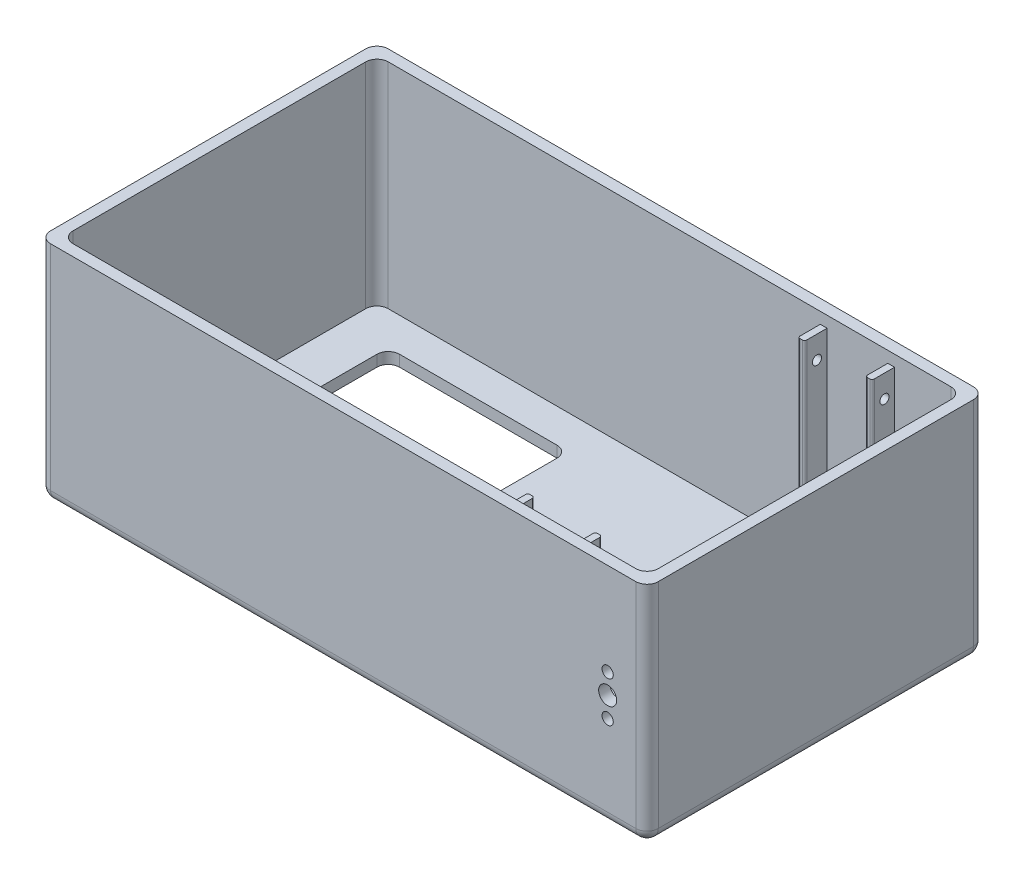
from build123d import *

# Parameters (mm, degrees)
SKETCH1_W               = 270
SKETCH1_H               = 150
OUTER_BOX_DEPTH         = 100
SKETCH2_W               = 260
SKETCH2_H               = 140
INNER_BOX_DEPTH         = 95
FILLET2_R               = 5
SKETCH3_W               = 80
SKETCH3_H               = 110
SCREEN_HOLE_DEPTH       = 77
FILLET3_R               = 5
SKETCH4_R               = 4
SKETCH4_R_2             = 2.5
WHEEL_HOLES_DEPTH       = 151
SKETCH5_R               = 14.5
CUT_EXTRUDE4_DEPTH      = 101
SKETCH9_R               = 1
CUT_EXTRUDE5_DEPTH      = 101
SKETCH10_W              = 3
SKETCH10_H              = 90
BOSS_EXTRUDE2_DEPTH     = 10
SKETCH11_W              = 3
SKETCH11_H              = 90
BOSS_EXTRUDE3_DEPTH     = 10
LPATTERN1_COUNT         = 2
LPATTERN1_PITCH         = 30
FILLET4_R               = 1
SKETCH13_R              = 2.024928201
SKETCH13_R_2            = 2
CUT_EXTRUDE6_DEPTH      = 60
CUT_EXTRUDE6_DEPTH_BACK = 11
SKETCH14_R              = 2
CUT_EXTRUDE7_DEPTH      = 63
CUT_EXTRUDE7_DEPTH_BACK = 16


with BuildPart() as part:
    # Sketch1 → Outer Box (new body)
    with BuildSketch(Plane(origin=(0, 0, 0), x_dir=(1, 0, 0), z_dir=(0, 1, 0))):
        Rectangle(SKETCH1_W, SKETCH1_H)
    extrude(amount=OUTER_BOX_DEPTH)

    # Sketch2 → Inner Box (cut)
    with BuildSketch(Plane(origin=(0, 100, 0), x_dir=(1, 0, 0), z_dir=(0, 1, 0))):
        Rectangle(SKETCH2_W, SKETCH2_H)
    extrude(amount=-INNER_BOX_DEPTH, mode=Mode.SUBTRACT)

    # Fillet2
    fillet2_edges = [part.edges().sort_by_distance(p)[0] for p in [
        (130, 52.5, 70),
        (-130, 52.5, 70),
        (-130, 52.5, -70),
        (130, 52.5, -70),
        (0, 0, 75),
        (-135, 0, 0),
        (0, 0, -75),
        (135, 0, 0),
        (135, 50, 75),
        (-135, 50, 75),
        (-135, 50, -75),
        (135, 50, -75),
    ]]
    fillet(fillet2_edges, radius=FILLET2_R)

    # Sketch3 → Screen Hole (cut)
    with BuildSketch(Plane.XZ):
        with Locations((-70, 0)):
            Rectangle(SKETCH3_W, SKETCH3_H)
    extrude(amount=-SCREEN_HOLE_DEPTH, mode=Mode.SUBTRACT)

    # Fillet3
    fillet3_edges = [part.edges().sort_by_distance(p)[0] for p in [
        (-110, 2.5, -55),
        (-110, 2.5, 55),
        (-30, 2.5, 55),
        (-30, 2.5, -55),
    ]]
    fillet(fillet3_edges, radius=FILLET3_R)

    # Sketch4 → Wheel Holes (cut, through all)
    with BuildSketch(Plane.XY.offset(75)):
        with Locations((117.5, 50)):
            Circle(SKETCH4_R)
        with Locations((117.5, 41)):
            Circle(SKETCH4_R_2)
        with Locations((117.5, 59)):
            Circle(SKETCH4_R_2)
    extrude(amount=-WHEEL_HOLES_DEPTH, mode=Mode.SUBTRACT)

    # Sketch5 → Cut-Extrude4 (cut, through all)
    with BuildSketch(Plane.XZ):
        Circle(SKETCH5_R)
    extrude(amount=-CUT_EXTRUDE4_DEPTH, mode=Mode.SUBTRACT)

    # Sketch9 → Cut-Extrude5 (cut, through all)
    with BuildSketch(Plane.XZ):
        with Locations((22.718468805, 62.780351251)):
            Circle(SKETCH9_R)
        with Locations((26.718468805, 62.780351251)):
            Circle(SKETCH9_R)
        with Locations((30.718468805, 62.780351251)):
            Circle(SKETCH9_R)
        with Locations((34.718468805, 62.780351251)):
            Circle(SKETCH9_R)
        with Locations((38.718468805, 62.780351251)):
            Circle(SKETCH9_R)
        with Locations((42.718468805, 62.780351251)):
            Circle(SKETCH9_R)
        with Locations((46.718468805, 62.780351251)):
            Circle(SKETCH9_R)
        with Locations((50.718468805, 62.780351251)):
            Circle(SKETCH9_R)
        with Locations((54.718468805, 62.780351251)):
            Circle(SKETCH9_R)
        with Locations((58.718468805, 62.780351251)):
            Circle(SKETCH9_R)
        with Locations((26.718468805, 57.780351251)):
            Circle(SKETCH9_R)
        with Locations((30.718468805, 57.780351251)):
            Circle(SKETCH9_R)
        with Locations((34.718468805, 57.780351251)):
            Circle(SKETCH9_R)
        with Locations((38.718468805, 57.780351251)):
            Circle(SKETCH9_R)
        with Locations((42.718468805, 57.780351251)):
            Circle(SKETCH9_R)
        with Locations((46.718468805, 57.780351251)):
            Circle(SKETCH9_R)
        with Locations((50.718468805, 57.780351251)):
            Circle(SKETCH9_R)
        with Locations((54.718468805, 57.780351251)):
            Circle(SKETCH9_R)
        with Locations((58.718468805, 57.780351251)):
            Circle(SKETCH9_R)
        with Locations((26.718468805, 52.780351251)):
            Circle(SKETCH9_R)
        with Locations((30.718468805, 52.780351251)):
            Circle(SKETCH9_R)
        with Locations((34.718468805, 52.780351251)):
            Circle(SKETCH9_R)
        with Locations((38.718468805, 52.780351251)):
            Circle(SKETCH9_R)
        with Locations((42.718468805, 52.780351251)):
            Circle(SKETCH9_R)
        with Locations((46.718468805, 52.780351251)):
            Circle(SKETCH9_R)
        with Locations((50.718468805, 52.780351251)):
            Circle(SKETCH9_R)
        with Locations((54.718468805, 52.780351251)):
            Circle(SKETCH9_R)
        with Locations((58.718468805, 52.780351251)):
            Circle(SKETCH9_R)
        with Locations((26.718468805, 47.780351251)):
            Circle(SKETCH9_R)
        with Locations((30.718468805, 47.780351251)):
            Circle(SKETCH9_R)
        with Locations((34.718468805, 47.780351251)):
            Circle(SKETCH9_R)
        with Locations((38.718468805, 47.780351251)):
            Circle(SKETCH9_R)
        with Locations((42.718468805, 47.780351251)):
            Circle(SKETCH9_R)
        with Locations((46.718468805, 47.780351251)):
            Circle(SKETCH9_R)
        with Locations((50.718468805, 47.780351251)):
            Circle(SKETCH9_R)
        with Locations((54.718468805, 47.780351251)):
            Circle(SKETCH9_R)
        with Locations((58.718468805, 47.780351251)):
            Circle(SKETCH9_R)
        with Locations((26.718468805, 42.780351251)):
            Circle(SKETCH9_R)
        with Locations((30.718468805, 42.780351251)):
            Circle(SKETCH9_R)
        with Locations((34.718468805, 42.780351251)):
            Circle(SKETCH9_R)
        with Locations((38.718468805, 42.780351251)):
            Circle(SKETCH9_R)
        with Locations((42.718468805, 42.780351251)):
            Circle(SKETCH9_R)
        with Locations((46.718468805, 42.780351251)):
            Circle(SKETCH9_R)
        with Locations((50.718468805, 42.780351251)):
            Circle(SKETCH9_R)
        with Locations((54.718468805, 42.780351251)):
            Circle(SKETCH9_R)
        with Locations((58.718468805, 42.780351251)):
            Circle(SKETCH9_R)
        with Locations((26.718468805, 37.780351251)):
            Circle(SKETCH9_R)
        with Locations((30.718468805, 37.780351251)):
            Circle(SKETCH9_R)
        with Locations((34.718468805, 37.780351251)):
            Circle(SKETCH9_R)
        with Locations((38.718468805, 37.780351251)):
            Circle(SKETCH9_R)
        with Locations((42.718468805, 37.780351251)):
            Circle(SKETCH9_R)
        with Locations((46.718468805, 37.780351251)):
            Circle(SKETCH9_R)
        with Locations((50.718468805, 37.780351251)):
            Circle(SKETCH9_R)
        with Locations((54.718468805, 37.780351251)):
            Circle(SKETCH9_R)
        with Locations((58.718468805, 37.780351251)):
            Circle(SKETCH9_R)
        with Locations((26.718468805, 32.780351251)):
            Circle(SKETCH9_R)
        with Locations((30.718468805, 32.780351251)):
            Circle(SKETCH9_R)
        with Locations((34.718468805, 32.780351251)):
            Circle(SKETCH9_R)
        with Locations((38.718468805, 32.780351251)):
            Circle(SKETCH9_R)
        with Locations((42.718468805, 32.780351251)):
            Circle(SKETCH9_R)
        with Locations((46.718468805, 32.780351251)):
            Circle(SKETCH9_R)
        with Locations((50.718468805, 32.780351251)):
            Circle(SKETCH9_R)
        with Locations((54.718468805, 32.780351251)):
            Circle(SKETCH9_R)
        with Locations((58.718468805, 32.780351251)):
            Circle(SKETCH9_R)
        with Locations((26.718468805, 27.780351251)):
            Circle(SKETCH9_R)
        with Locations((30.718468805, 27.780351251)):
            Circle(SKETCH9_R)
        with Locations((34.718468805, 27.780351251)):
            Circle(SKETCH9_R)
        with Locations((38.718468805, 27.780351251)):
            Circle(SKETCH9_R)
        with Locations((42.718468805, 27.780351251)):
            Circle(SKETCH9_R)
        with Locations((46.718468805, 27.780351251)):
            Circle(SKETCH9_R)
        with Locations((50.718468805, 27.780351251)):
            Circle(SKETCH9_R)
        with Locations((54.718468805, 27.780351251)):
            Circle(SKETCH9_R)
        with Locations((58.718468805, 27.780351251)):
            Circle(SKETCH9_R)
        with Locations((26.718468805, 22.780351251)):
            Circle(SKETCH9_R)
        with Locations((30.718468805, 22.780351251)):
            Circle(SKETCH9_R)
        with Locations((34.718468805, 22.780351251)):
            Circle(SKETCH9_R)
        with Locations((38.718468805, 22.780351251)):
            Circle(SKETCH9_R)
        with Locations((42.718468805, 22.780351251)):
            Circle(SKETCH9_R)
        with Locations((46.718468805, 22.780351251)):
            Circle(SKETCH9_R)
        with Locations((50.718468805, 22.780351251)):
            Circle(SKETCH9_R)
        with Locations((54.718468805, 22.780351251)):
            Circle(SKETCH9_R)
        with Locations((58.718468805, 22.780351251)):
            Circle(SKETCH9_R)
        with Locations((26.718468805, 17.780351251)):
            Circle(SKETCH9_R)
        with Locations((30.718468805, 17.780351251)):
            Circle(SKETCH9_R)
        with Locations((34.718468805, 17.780351251)):
            Circle(SKETCH9_R)
        with Locations((38.718468805, 17.780351251)):
            Circle(SKETCH9_R)
        with Locations((42.718468805, 17.780351251)):
            Circle(SKETCH9_R)
        with Locations((46.718468805, 17.780351251)):
            Circle(SKETCH9_R)
        with Locations((50.718468805, 17.780351251)):
            Circle(SKETCH9_R)
        with Locations((54.718468805, 17.780351251)):
            Circle(SKETCH9_R)
        with Locations((58.718468805, 17.780351251)):
            Circle(SKETCH9_R)
        with Locations((26.718468805, 12.780351251)):
            Circle(SKETCH9_R)
        with Locations((30.718468805, 12.780351251)):
            Circle(SKETCH9_R)
        with Locations((34.718468805, 12.780351251)):
            Circle(SKETCH9_R)
        with Locations((38.718468805, 12.780351251)):
            Circle(SKETCH9_R)
        with Locations((42.718468805, 12.780351251)):
            Circle(SKETCH9_R)
        with Locations((46.718468805, 12.780351251)):
            Circle(SKETCH9_R)
        with Locations((50.718468805, 12.780351251)):
            Circle(SKETCH9_R)
        with Locations((54.718468805, 12.780351251)):
            Circle(SKETCH9_R)
        with Locations((58.718468805, 12.780351251)):
            Circle(SKETCH9_R)
        with Locations((22.718468805, 57.780351251)):
            Circle(SKETCH9_R)
        with Locations((22.718468805, 52.780351251)):
            Circle(SKETCH9_R)
        with Locations((22.718468805, 47.780351251)):
            Circle(SKETCH9_R)
        with Locations((22.718468805, 42.780351251)):
            Circle(SKETCH9_R)
        with Locations((22.718468805, 37.780351251)):
            Circle(SKETCH9_R)
        with Locations((22.718468805, 32.780351251)):
            Circle(SKETCH9_R)
        with Locations((22.718468805, 27.780351251)):
            Circle(SKETCH9_R)
        with Locations((22.718468805, 22.780351251)):
            Circle(SKETCH9_R)
        with Locations((22.718468805, 17.780351251)):
            Circle(SKETCH9_R)
        with Locations((22.718468805, 12.780351251)):
            Circle(SKETCH9_R)
    extrude(amount=-CUT_EXTRUDE5_DEPTH, mode=Mode.SUBTRACT)

    # Sketch10 → Boss-Extrude2 (add)
    with BuildSketch(Plane.XY.offset(-70)):
        with Locations((98.5, 50)):
            Rectangle(SKETCH10_W, SKETCH10_H)
    boss_extrude2 = extrude(amount=BOSS_EXTRUDE2_DEPTH)

    # Sketch11 → Boss-Extrude3 (add)
    with BuildSketch(Plane(origin=(0, 0, 70), x_dir=(-1, 0, 0), z_dir=(0, 0, -1))):
        with Locations((-98.5, 50)):
            Rectangle(SKETCH11_W, SKETCH11_H)
    boss_extrude3 = extrude(amount=BOSS_EXTRUDE3_DEPTH)

    # LPattern1: Boss-Extrude2, Boss-Extrude3 ×2
    with Locations(*[(-i * LPATTERN1_PITCH, 0, 0) for i in range(1, LPATTERN1_COUNT)]):
        add(boss_extrude2)
        add(boss_extrude3)

    # Fillet4
    fillet4_edges = [part.edges().sort_by_distance(p)[0] for p in [
        (97, 50, -60),
        (100, 50, -60),
        (97, 50, 60),
        (100, 50, 60),
        (67, 50, -60),
        (70, 50, -60),
        (67, 50, 60),
        (70, 50, 60),
    ]]
    fillet(fillet4_edges, radius=FILLET4_R)

    # Sketch13 → Cut-Extrude6 (cut, two sides)
    with BuildSketch(Plane.ZY.offset(-97)) as cut_extrude6_sk:
        with Locations((-65.5, 85)):
            Circle(SKETCH13_R)
        with Locations((-65.5, 15)):
            Circle(SKETCH13_R_2)
    extrude(amount=CUT_EXTRUDE6_DEPTH, mode=Mode.SUBTRACT)
    extrude(cut_extrude6_sk.sketch, amount=-CUT_EXTRUDE6_DEPTH_BACK, mode=Mode.SUBTRACT)

    # Sketch14 → Cut-Extrude7 (cut, two sides)
    with BuildSketch(Plane.ZY.offset(-97)) as cut_extrude7_sk:
        with Locations((65.5, 85)):
            Circle(SKETCH14_R)
        with Locations((65.5, 15)):
            Circle(SKETCH14_R)
    extrude(amount=CUT_EXTRUDE7_DEPTH, mode=Mode.SUBTRACT)
    extrude(cut_extrude7_sk.sketch, amount=-CUT_EXTRUDE7_DEPTH_BACK, mode=Mode.SUBTRACT)


solid = part.part
